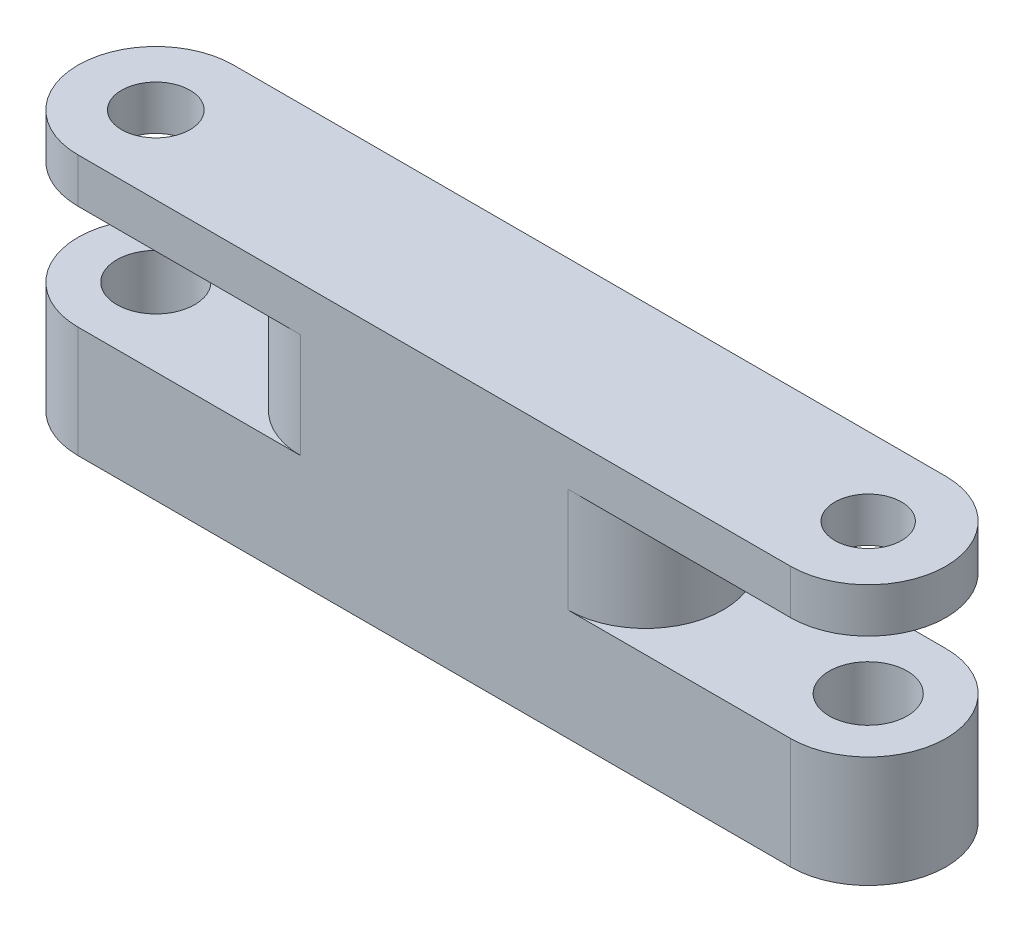
from build123d import *

# Parameters (mm, degrees)
CROQUIS1_R              = 1.75
SALIENTE_EXTRUIR1_DEPTH = 5
CROQUIS2_R              = 3.493601412
CROQUIS2_W              = 12
CROQUIS2_H              = 6.987202823
SALIENTE_EXTRUIR2_DEPTH = 4.7
CROQUIS3_R              = 1.537305571
CROQUIS3_R_2            = 1.5
SALIENTE_EXTRUIR3_DEPTH = 2


with BuildPart() as part:
    # Croquis1 → Saliente-Extruir1 (new body)
    with BuildSketch(Plane(origin=(0, 0, 0), x_dir=(1, 0, 0), z_dir=(0, 1, 0))):
        with BuildLine():
            Line((36.568555692, 6.987202823), (4.568555692, 6.987202823))
            ThreePointArc((4.568555692, 6.987202823), (1.07495428, 3.493601412), (4.568555692, 0))
            Line((4.568555692, 0), (36.568555692, 0))
            ThreePointArc((36.568555692, 0), (40.062157104, 3.493601412), (36.568555692, 6.987202823))
        make_face()
        with Locations((4.568555692, 3.493601412)):
            Circle(CROQUIS1_R, mode=Mode.SUBTRACT)
        with Locations((36.568555692, 3.493601412)):
            Circle(CROQUIS1_R, mode=Mode.SUBTRACT)
    extrude(amount=SALIENTE_EXTRUIR1_DEPTH)

    # Croquis2 → Saliente-Extruir2 (add)
    with BuildSketch(Plane(origin=(0, 5, 0), x_dir=(1, 0, 0), z_dir=(0, 1, 0))):
        with Locations((26.568555692, 3.493601412)):
            Circle(CROQUIS2_R)
        with Locations((14.568555692, 3.493601412)):
            Circle(CROQUIS2_R)
        with Locations((20.568555692, 3.493601412)):
            Rectangle(CROQUIS2_W, CROQUIS2_H)
    extrude(amount=SALIENTE_EXTRUIR2_DEPTH)

    # Croquis3 → Saliente-Extruir3 (add)
    with BuildSketch(Plane(origin=(0, 9.7, 0), x_dir=(1, 0, 0), z_dir=(0, 1, 0))):
        with BuildLine():
            Line((4.568555692, 6.987202823), (36.568555692, 6.987202823))
            ThreePointArc((36.568555692, 6.987202823), (40.062157104, 3.493601412), (36.568555692, 0))
            Line((36.568555692, 0), (4.568555692, 0))
            ThreePointArc((4.568555692, 0), (1.07495428, 3.493601412), (4.568555692, 6.987202823))
        make_face()
        with Locations((4.568555692, 3.493601412)):
            Circle(CROQUIS3_R, mode=Mode.SUBTRACT)
        with Locations((36.568555692, 3.493601412)):
            Circle(CROQUIS3_R_2, mode=Mode.SUBTRACT)
    extrude(amount=SALIENTE_EXTRUIR3_DEPTH)


solid = part.part
